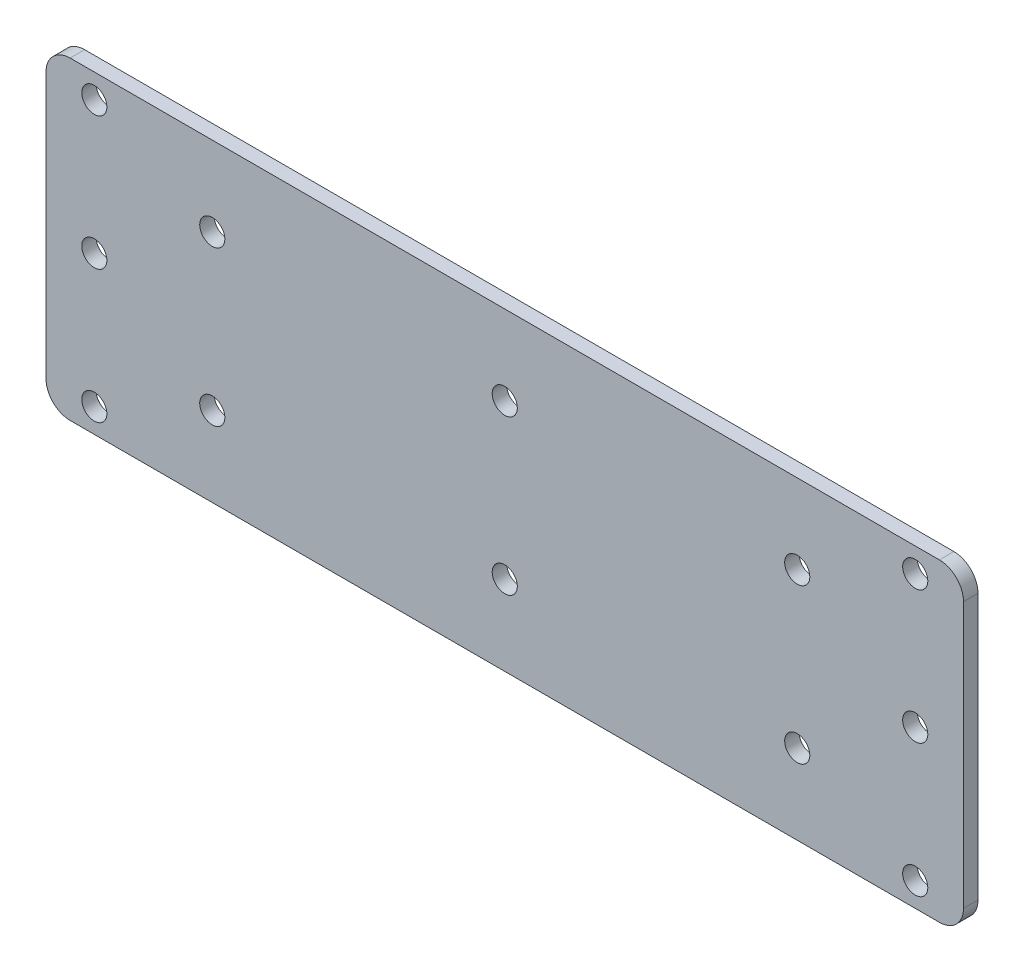
from build123d import *

# Parameters (mm, degrees)
SKETCH_1_W           = 250
SKETCH_1_H           = 65
SKETCH_1_R           = 2.5
EXTRUDE_1_DEPTH      = 3
FILLET_1_R           = 3
CUT_EXTRUDE_3_DEPTH  = 4
FILLET_2_R           = 3
SKETCH_6_W           = 30
SKETCH_6_H           = 65
CUT_EXTRUDE_4_DEPTH  = 5
CUT_EXTRUDE_7_DEPTH  = 5
FILLET_3_R           = 5
SKETCH_8_R           = 2.5
EXTRUDE_2_DEPTH      = 3
SKETCH_10_R          = 2.5
CUT_EXTRUDE_8_DEPTH  = 3
SKETCH_13_R          = 2.5
EXTRUDE_3_DEPTH      = 3
SKETCH_15_R          = 2.5
EXTRUDE_4_DEPTH      = 3
SKETCH_18_R          = 2.5
CUT_EXTRUDE_11_DEPTH = 4
SKETCH_20_R          = 2.5
CUT_EXTRUDE_12_DEPTH = 10
SKETCH_21_R          = 2.6
CUT_EXTRUDE_13_DEPTH = 4


with BuildPart() as part:
    # 草图1 → 凸台-拉伸1 (new body)
    with BuildSketch(Plane.XY):
        Rectangle(SKETCH_1_W, SKETCH_1_H)
        with Locations((-70, 16)):
            Circle(SKETCH_1_R, mode=Mode.SUBTRACT)
        with Locations((-70, -16)):
            Circle(SKETCH_1_R, mode=Mode.SUBTRACT)
        with Locations((70, -16)):
            Circle(SKETCH_1_R, mode=Mode.SUBTRACT)
        with Locations((70, 16)):
            Circle(SKETCH_1_R, mode=Mode.SUBTRACT)
        with Locations((0, 16)):
            Circle(SKETCH_1_R, mode=Mode.SUBTRACT)
        with Locations((0, -16)):
            Circle(SKETCH_1_R, mode=Mode.SUBTRACT)
    extrude(amount=EXTRUDE_1_DEPTH)

    # 圆角1
    fillet_1_edges = [part.edges().sort_by_distance(p)[0] for p in [
        (125, -32.5, 1.5),
        (-125, -32.5, 1.5),
        (-125, 32.5, 1.5),
        (125, 32.5, 1.5),
    ]]
    fillet(fillet_1_edges, radius=FILLET_1_R)

    # 草图4 → 切除-拉伸3 (cut, through all)
    with BuildSketch(Plane(origin=(0, 0, 0), x_dir=(-1, 0, 0), z_dir=(0, 0, -1))):
        with BuildLine():
            Line((-113.82, 32.5), (-122, 32.5))
            ThreePointArc((-122, 32.5), (-124.121320344, 31.621320344), (-125, 29.5))
            Line((-125, 29.5), (-125, -29.5))
            ThreePointArc((-125, -29.5), (-124.121320344, -31.621320344), (-122, -32.5))
            Line((-122, -32.5), (-113.82, -32.5))
            Line((-113.82, -32.5), (-113.82, 32.5))
        make_face()
    extrude(amount=-CUT_EXTRUDE_3_DEPTH, mode=Mode.SUBTRACT)

    # 圆角2
    fillet_2_edges = [part.edges().sort_by_distance(p)[0] for p in [
        (113.82, 32.5, 1.5),
        (113.82, -32.5, 1.5),
    ]]
    fillet(fillet_2_edges, radius=FILLET_2_R)

    # 草图6 → 切除-拉伸4 (cut)
    with BuildSketch(Plane.XY.offset(3)):
        with Locations((-110, 0)):
            Rectangle(SKETCH_6_W, SKETCH_6_H)
    extrude(amount=-CUT_EXTRUDE_4_DEPTH, mode=Mode.SUBTRACT)

    # 草图7 → 切除-拉伸7 (cut)
    with BuildSketch(Plane.XY.offset(3)):
        Polygon((113.82, -32.860309594), (113.82, 33.556993736), (94.996170136, 32.5), (94.996170136, -32.5), align=None)
    extrude(amount=-CUT_EXTRUDE_7_DEPTH, mode=Mode.SUBTRACT)

    # 圆角3
    fillet_3_edges = [part.edges().sort_by_distance(p)[0] for p in [
        (-95, 32.5, 1.5),
        (-95, -32.5, 1.5),
        (94.996170136, -32.5, 1.5),
        (94.996170136, 32.5, 1.5),
    ]]
    fillet(fillet_3_edges, radius=FILLET_3_R)

    # 草图8 → 凸台-拉伸2 (add)
    with BuildSketch(Plane(origin=(0, 0, 0), x_dir=(-1, 0, 0), z_dir=(0, 0, -1))):
        with Locations((70, 16)):
            Circle(SKETCH_8_R)
        with Locations((70, -16)):
            Circle(SKETCH_8_R)
        with Locations((-70, 16)):
            Circle(SKETCH_8_R)
        with Locations((-70, -16)):
            Circle(SKETCH_8_R)
    extrude(amount=-EXTRUDE_2_DEPTH)

    # 草图10 → 切除-拉伸8 (cut)
    with BuildSketch(Plane(origin=(0, 0, 0), x_dir=(-1, 0, 0), z_dir=(0, 0, -1))):
        with Locations((-60.563944815, 16.029236842)):
            Circle(SKETCH_10_R)
        with Locations((-60.563944815, -15.970763158)):
            Circle(SKETCH_10_R)
        with Locations((62.89412836, 16.029236842)):
            Circle(SKETCH_10_R)
        with Locations((62.89412836, -15.970763158)):
            Circle(SKETCH_10_R)
    extrude(amount=-CUT_EXTRUDE_8_DEPTH, mode=Mode.SUBTRACT)

    # 草图13 → 凸台-拉伸3 (add)
    with BuildSketch(Plane(origin=(0, 0, 0), x_dir=(-1, 0, 0), z_dir=(0, 0, -1))):
        with Locations((62.89412836, 16.029236842)):
            Circle(SKETCH_13_R)
        with Locations((62.89412836, -15.970763158)):
            Circle(SKETCH_13_R)
    extrude(amount=-EXTRUDE_3_DEPTH)

    # 草图15 → 凸台-拉伸4 (add)
    with BuildSketch(Plane(origin=(0, 0, 0), x_dir=(-1, 0, 0), z_dir=(0, 0, -1))):
        with Locations((62.89412836, 16.029236843)):
            Circle(SKETCH_15_R)
        with Locations((62.89412836, -15.970763157)):
            Circle(SKETCH_15_R)
    extrude(amount=-EXTRUDE_4_DEPTH)

    # 草图18 → 切除-拉伸11 (cut, through all)
    with BuildSketch(Plane(origin=(0, 0, 0), x_dir=(-1, 0, 0), z_dir=(0, 0, -1))):
        with Locations((-84.996170136, 27.5)):
            Circle(SKETCH_18_R)
        with Locations((-84.996170136, -27.5)):
            Circle(SKETCH_18_R)
    cut_extrude_11 = extrude(amount=-CUT_EXTRUDE_11_DEPTH, mode=Mode.SUBTRACT)

    # 镜向1: 切除-拉伸11 across plane
    add(cut_extrude_11.mirror(Plane(origin=(-0.001914932, 0, 0), x_dir=(0, 0, 1), z_dir=(1, 0, 0))), mode=Mode.SUBTRACT)

    # 草图20 → 切除-拉伸12 (cut)
    with BuildSketch(Plane(origin=(0, 0, 0), x_dir=(-1, 0, 0), z_dir=(0, 0, -1))):
        with Locations((85, 0)):
            Circle(SKETCH_20_R)
        with Locations((-84.996170136, 0)):
            Circle(SKETCH_20_R)
    extrude(amount=-CUT_EXTRUDE_12_DEPTH, mode=Mode.SUBTRACT)

    # 草图21 → 切除-拉伸13 (cut, through all)
    with BuildSketch(Plane(origin=(0, 0, 0), x_dir=(-1, 0, 0), z_dir=(0, 0, -1))):
        with Locations((-84.996170136, 27.5)):
            Circle(SKETCH_21_R)
        with Locations((-60.563944815, 16.029236842)):
            Circle(SKETCH_21_R)
        with Locations((-84.996170136, 0)):
            Circle(SKETCH_21_R)
        with Locations((-60.563944815, -15.970763158)):
            Circle(SKETCH_21_R)
        with Locations((-84.996170136, -27.512746042)):
            Circle(SKETCH_21_R)
        with Locations((0.001914932, 16.029236842)):
            Circle(SKETCH_21_R)
        with Locations((0.001914932, -15.970763158)):
            Circle(SKETCH_21_R)
        with Locations((85, -27.512746042)):
            Circle(SKETCH_21_R)
        with Locations((60.567774678, -15.970763158)):
            Circle(SKETCH_21_R)
        with Locations((85, 0)):
            Circle(SKETCH_21_R)
        with Locations((60.567774678, 16.029236842)):
            Circle(SKETCH_21_R)
        with Locations((85, 27.5)):
            Circle(SKETCH_21_R)
    extrude(amount=-CUT_EXTRUDE_13_DEPTH, mode=Mode.SUBTRACT)


solid = part.part
